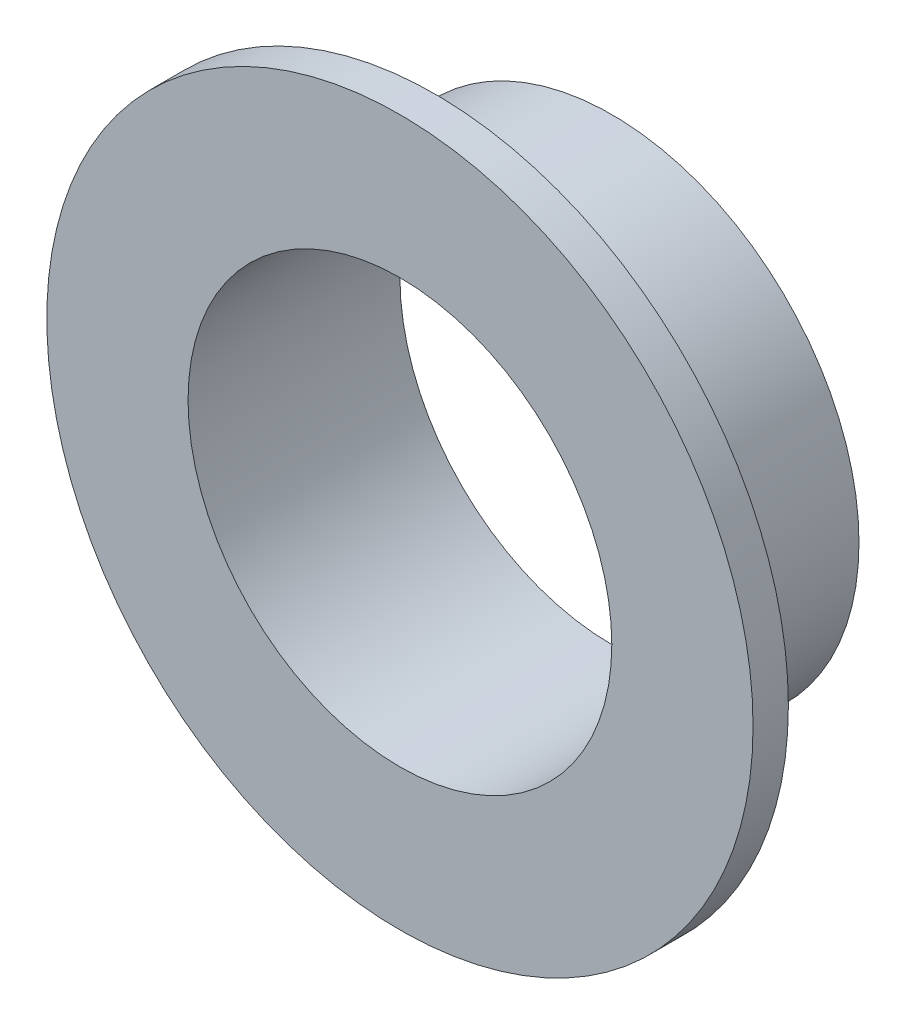
from build123d import *

# Parameters (mm, degrees)
SKETCH1_R           = 7
SKETCH1_R_2         = 6
BOSS_EXTRUDE1_DEPTH = 5
SKETCH3_R           = 10
SKETCH3_R_2         = 6
BOSS_EXTRUDE2_DEPTH = 1


with BuildPart() as part:
    # Sketch1 → Boss-Extrude1 (new body)
    with BuildSketch(Plane.XY):
        Circle(SKETCH1_R)
        Circle(SKETCH1_R_2, mode=Mode.SUBTRACT)
    extrude(amount=BOSS_EXTRUDE1_DEPTH)

    # Sketch3 → Boss-Extrude2 (add)
    with BuildSketch(Plane.XY.offset(5)):
        Circle(SKETCH3_R)
        Circle(SKETCH3_R_2, mode=Mode.SUBTRACT)
    extrude(amount=BOSS_EXTRUDE2_DEPTH)


solid = part.part
